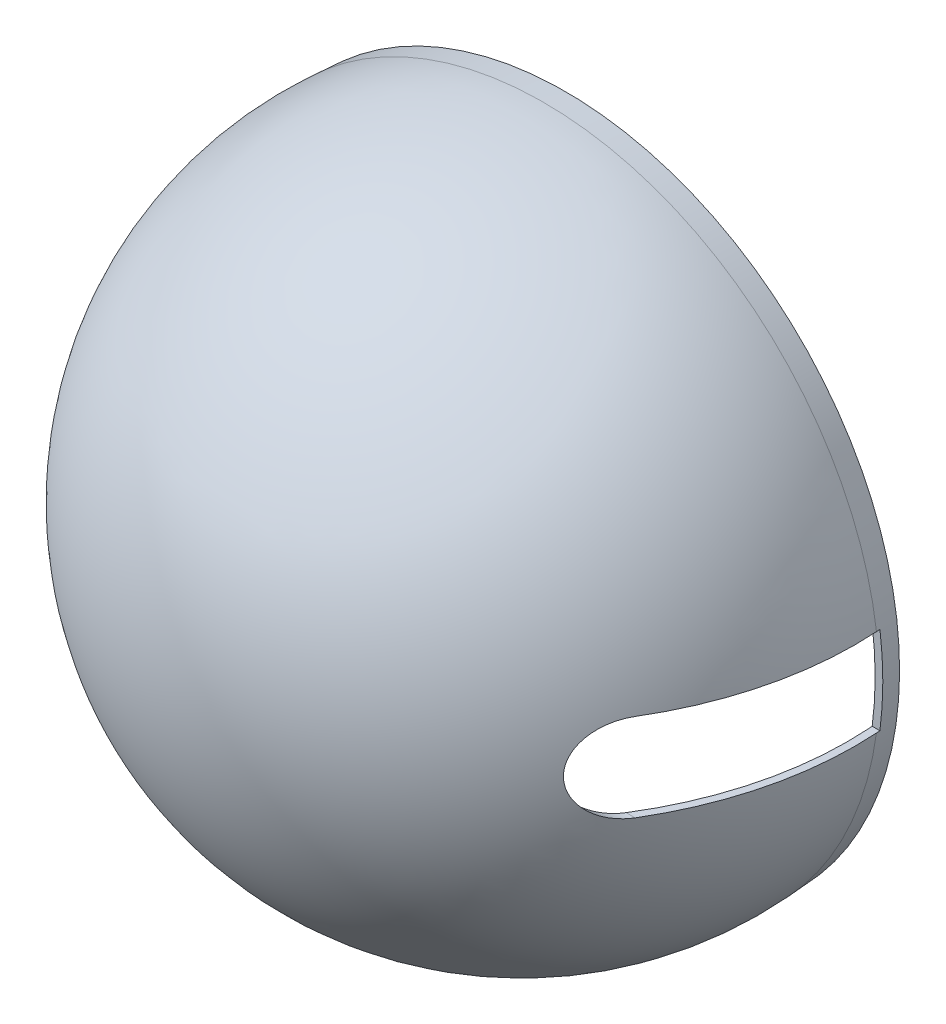
from build123d import *

# Parameters (mm, degrees)
CUT_EXTRUDE1_DEPTH = 37.631109163


with BuildPart() as part:
    # Sketch2 → Revolve1 (revolve)
    with BuildSketch(Plane(origin=(0, -7.374853929, -7.41), x_dir=(-1, 0, 0), z_dir=(0, -1, 0))):
        with BuildLine():
            Line((50.149352541, -7.41), (50.339283308, -10.312639962))
            ThreePointArc((50.339283308, -10.312639962), (38.805254547, -42.539770141), (7.4, -56.153429675))
            Line((7.4, -56.153429675), (7.4, -57.153429675))
            ThreePointArc((7.4, -57.153429675), (39.535081297, -43.22340229), (51.337149367, -10.247345792))
            Line((51.337149367, -10.247345792), (51.151491045, -7.41))
            Line((51.151491045, -7.41), (50.149352541, -7.41))
        make_face()
    revolve(axis=Axis((-7.4, -7.374853929, -2), (0, 0, 1)))

    # Sketch3 → Cut-Extrude1 (cut, through all)
    with BuildSketch(Plane(origin=(0, 0, 0), x_dir=(0, 0, -1), z_dir=(1, 0, 0))):
        with BuildLine():
            Line((-2.348097087, -13.16), (-28.25, -13.16))
            ThreePointArc((-28.25, -13.16), (-34, -7.41), (-28.25, -1.66))
            Line((-28.25, -1.66), (-2.348097087, -1.66))
            Line((-2.348097087, -1.66), (-2.348097087, -13.16))
        make_face()
    extrude(amount=CUT_EXTRUDE1_DEPTH, mode=Mode.SUBTRACT)


solid = part.part
